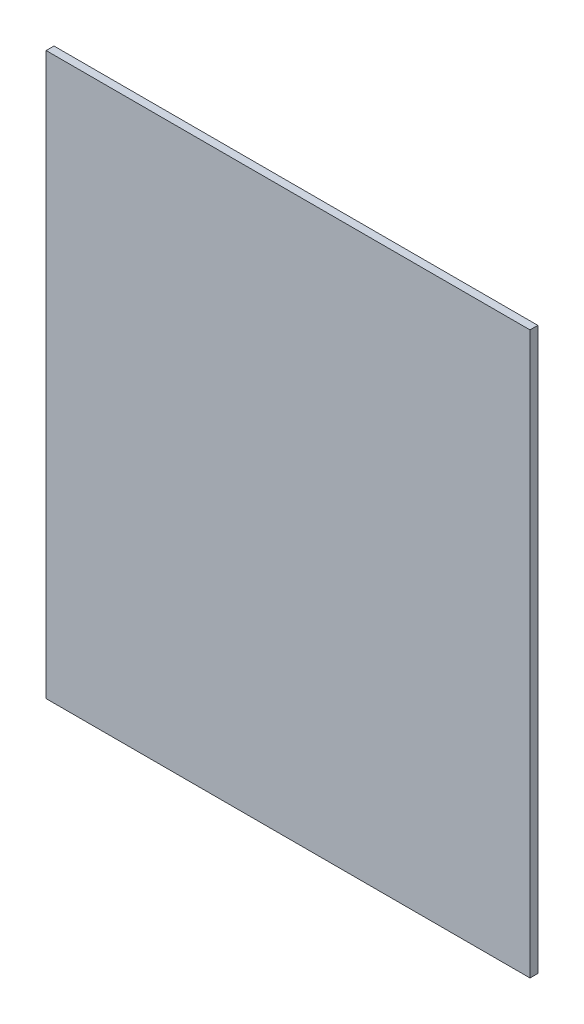
from build123d import *

# Parameters (mm, degrees)
ESQUISSE1_W        = 258.6
ESQUISSE1_H        = 300
BOSS_EXTRU_1_DEPTH = 4.2


with BuildPart() as part:
    # Esquisse1 → Boss.-Extru.1 (new body)
    with BuildSketch(Plane.XY):
        with Locations((23.228291112, 81.547058824)):
            Rectangle(ESQUISSE1_W, ESQUISSE1_H)
    extrude(amount=BOSS_EXTRU_1_DEPTH)


solid = part.part
